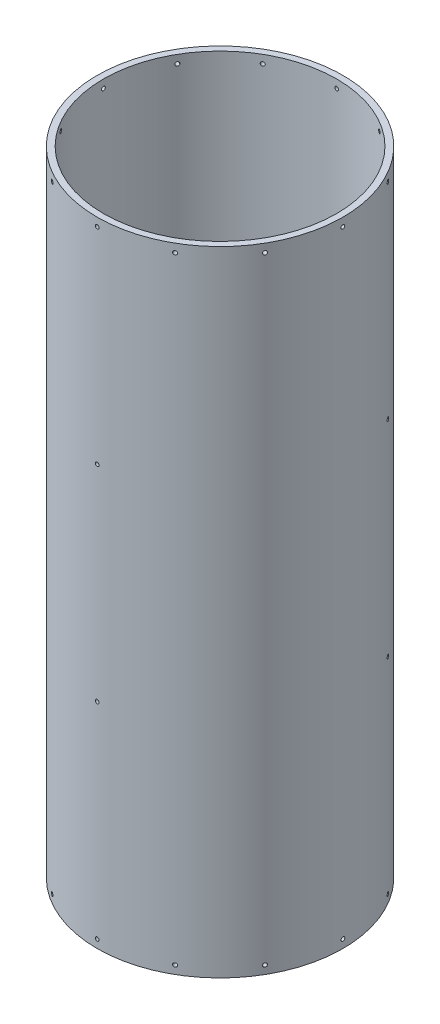
from build123d import *

# Parameters (mm, degrees)
SKETCH1_R                = 93.6625
SKETCH1_R_2              = 88.9
BOSS_EXTRUDE1_DEPTH      = 241.427
SKETCH3_R                = 1.4351
CUT_EXTRUDE1_DEPTH       = 19.304
CIRPATTERN1_COUNT        = 12
MIRROR1_COPY_1_SKETCH_R  = 1.4351
MIRROR1_COPY_1_DEPTH     = 19.304
MIRROR1_COPY_2_SKETCH_R  = 1.4351
MIRROR1_COPY_2_DEPTH     = 19.304
MIRROR1_COPY_3_SKETCH_R  = 1.4351
MIRROR1_COPY_3_DEPTH     = 19.304
MIRROR1_COPY_4_SKETCH_R  = 1.4351
MIRROR1_COPY_4_DEPTH     = 19.304
MIRROR1_COPY_5_SKETCH_R  = 1.4351
MIRROR1_COPY_5_DEPTH     = 19.304
MIRROR1_COPY_6_SKETCH_R  = 1.4351
MIRROR1_COPY_6_DEPTH     = 19.304
MIRROR1_COPY_7_SKETCH_R  = 1.4351
MIRROR1_COPY_7_DEPTH     = 19.304
MIRROR1_COPY_8_SKETCH_R  = 1.4351
MIRROR1_COPY_8_DEPTH     = 19.304
MIRROR1_COPY_9_SKETCH_R  = 1.4351
MIRROR1_COPY_9_DEPTH     = 19.304
MIRROR1_COPY_10_SKETCH_R = 1.4351
MIRROR1_COPY_10_DEPTH    = 19.304
MIRROR1_COPY_11_SKETCH_R = 1.4351
MIRROR1_COPY_11_DEPTH    = 19.304
SKETCH4_R                = 1.4351
CUT_EXTRUDE2_DEPTH       = 25.146
CIRPATTERN2_COUNT        = 3


with BuildPart() as part:
    # Sketch1 → Boss-Extrude1 (new body, symmetric)
    with BuildSketch(Plane(origin=(0, 0, 0), x_dir=(1, 0, 0), z_dir=(0, 1, 0))):
        Circle(SKETCH1_R)
        Circle(SKETCH1_R_2, mode=Mode.SUBTRACT)
    extrude(amount=BOSS_EXTRUDE1_DEPTH, both=True)

    # Sketch3 → Cut-Extrude1 (cut)
    with BuildSketch(Plane.XY.offset(93.6625)):
        with Locations((0, -235.077)):
            Circle(SKETCH3_R)
    cut_extrude1 = extrude(amount=-CUT_EXTRUDE1_DEPTH, mode=Mode.SUBTRACT)

    # CirPattern1: Cut-Extrude1 ×12 about axis
    cirpattern1_axis = Axis((0, 241.427, 0), (0, -1, 0))
    for i in range(1, CIRPATTERN1_COUNT):
        add(cut_extrude1.rotate(cirpattern1_axis, i * 360 / CIRPATTERN1_COUNT), mode=Mode.SUBTRACT)

    # Mirror1: Cut-Extrude1 across plane
    add(cut_extrude1.mirror(Plane.ZX), mode=Mode.SUBTRACT)

    # Mirror1 copy 1 sketch → Mirror1 copy 1 (cut)
    with BuildSketch(Plane(origin=(-46.83125, 0, 81.114104382), x_dir=(0.866025404, 0, 0.5), z_dir=(-0.5, 0, 0.866025404))):
        with Locations((0, 235.077)):
            Circle(MIRROR1_COPY_1_SKETCH_R)
    extrude(amount=-MIRROR1_COPY_1_DEPTH, mode=Mode.SUBTRACT)

    # Mirror1 copy 2 sketch → Mirror1 copy 2 (cut)
    with BuildSketch(Plane(origin=(-81.114104382, 0, 46.83125), x_dir=(0.5, 0, 0.866025404), z_dir=(-0.866025404, 0, 0.5))):
        with Locations((0, 235.077)):
            Circle(MIRROR1_COPY_2_SKETCH_R)
    extrude(amount=-MIRROR1_COPY_2_DEPTH, mode=Mode.SUBTRACT)

    # Mirror1 copy 3 sketch → Mirror1 copy 3 (cut)
    with BuildSketch(Plane.ZY.offset(93.6625)):
        with Locations((0, 235.077)):
            Circle(MIRROR1_COPY_3_SKETCH_R)
    extrude(amount=-MIRROR1_COPY_3_DEPTH, mode=Mode.SUBTRACT)

    # Mirror1 copy 4 sketch → Mirror1 copy 4 (cut)
    with BuildSketch(Plane(origin=(-81.114104382, 0, -46.83125), x_dir=(-0.5, 0, 0.866025404), z_dir=(-0.866025404, 0, -0.5))):
        with Locations((0, 235.077)):
            Circle(MIRROR1_COPY_4_SKETCH_R)
    extrude(amount=-MIRROR1_COPY_4_DEPTH, mode=Mode.SUBTRACT)

    # Mirror1 copy 5 sketch → Mirror1 copy 5 (cut)
    with BuildSketch(Plane(origin=(-46.83125, 0, -81.114104382), x_dir=(-0.866025404, 0, 0.5), z_dir=(-0.5, 0, -0.866025404))):
        with Locations((0, 235.077)):
            Circle(MIRROR1_COPY_5_SKETCH_R)
    extrude(amount=-MIRROR1_COPY_5_DEPTH, mode=Mode.SUBTRACT)

    # Mirror1 copy 6 sketch → Mirror1 copy 6 (cut)
    with BuildSketch(Plane(origin=(0, 0, -93.6625), x_dir=(-1, 0, 0), z_dir=(0, 0, -1))):
        with Locations((0, 235.077)):
            Circle(MIRROR1_COPY_6_SKETCH_R)
    extrude(amount=-MIRROR1_COPY_6_DEPTH, mode=Mode.SUBTRACT)

    # Mirror1 copy 7 sketch → Mirror1 copy 7 (cut)
    with BuildSketch(Plane(origin=(46.83125, 0, -81.114104382), x_dir=(-0.866025404, 0, -0.5), z_dir=(0.5, 0, -0.866025404))):
        with Locations((0, 235.077)):
            Circle(MIRROR1_COPY_7_SKETCH_R)
    extrude(amount=-MIRROR1_COPY_7_DEPTH, mode=Mode.SUBTRACT)

    # Mirror1 copy 8 sketch → Mirror1 copy 8 (cut)
    with BuildSketch(Plane(origin=(81.114104382, 0, -46.83125), x_dir=(-0.5, 0, -0.866025404), z_dir=(0.866025404, 0, -0.5))):
        with Locations((0, 235.077)):
            Circle(MIRROR1_COPY_8_SKETCH_R)
    extrude(amount=-MIRROR1_COPY_8_DEPTH, mode=Mode.SUBTRACT)

    # Mirror1 copy 9 sketch → Mirror1 copy 9 (cut)
    with BuildSketch(Plane(origin=(93.6625, 0, 0), x_dir=(0, 0, -1), z_dir=(1, 0, 0))):
        with Locations((0, 235.077)):
            Circle(MIRROR1_COPY_9_SKETCH_R)
    extrude(amount=-MIRROR1_COPY_9_DEPTH, mode=Mode.SUBTRACT)

    # Mirror1 copy 10 sketch → Mirror1 copy 10 (cut)
    with BuildSketch(Plane(origin=(81.114104382, 0, 46.83125), x_dir=(0.5, 0, -0.866025404), z_dir=(0.866025404, 0, 0.5))):
        with Locations((0, 235.077)):
            Circle(MIRROR1_COPY_10_SKETCH_R)
    extrude(amount=-MIRROR1_COPY_10_DEPTH, mode=Mode.SUBTRACT)

    # Mirror1 copy 11 sketch → Mirror1 copy 11 (cut)
    with BuildSketch(Plane(origin=(46.83125, 0, 81.114104382), x_dir=(0.866025404, 0, -0.5), z_dir=(0.5, 0, 0.866025404))):
        with Locations((0, 235.077)):
            Circle(MIRROR1_COPY_11_SKETCH_R)
    extrude(amount=-MIRROR1_COPY_11_DEPTH, mode=Mode.SUBTRACT)

    # Sketch4 → Cut-Extrude2 (cut)
    with BuildSketch(Plane.XY.offset(93.6625)):
        with Locations((0, -78.359)):
            Circle(SKETCH4_R)
        with Locations((0, 78.359)):
            Circle(SKETCH4_R)
    cut_extrude2 = extrude(amount=-CUT_EXTRUDE2_DEPTH, mode=Mode.SUBTRACT)

    # CirPattern2: Cut-Extrude2 ×3 about axis
    cirpattern2_axis = Axis((0, 241.427, 0), (0, -1, 0))
    for i in range(1, CIRPATTERN2_COUNT):
        add(cut_extrude2.rotate(cirpattern2_axis, i * 360 / CIRPATTERN2_COUNT), mode=Mode.SUBTRACT)


solid = part.part
